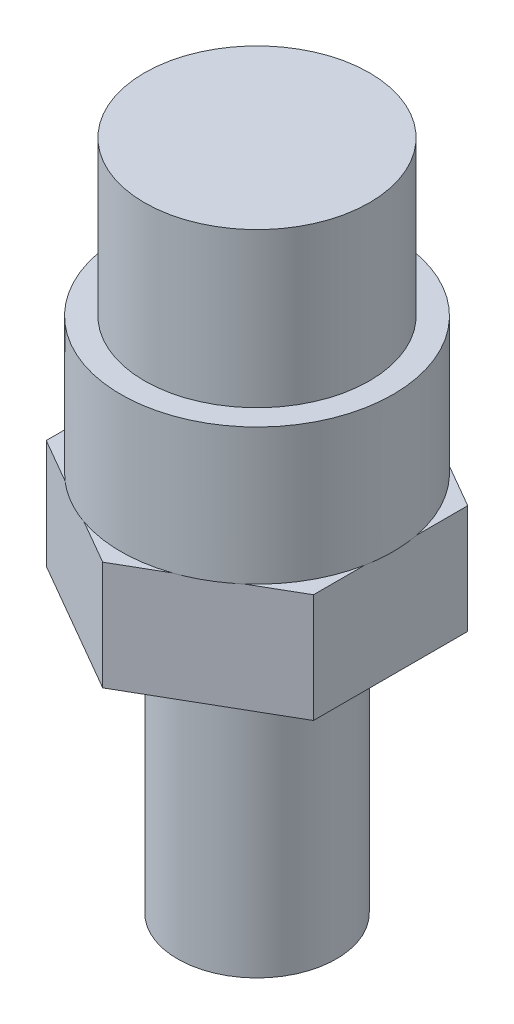
from build123d import *

# Parameters (mm, degrees)
CUT_EXTRUDE1_DEPTH = 7.62


with BuildPart() as part:
    # Sketch1 → Revolve1 (revolve)
    with BuildSketch(Plane.XY):
        Polygon((0, 0), (5.55625, 0), (5.55625, 19.05), (10.795, 19.05), (10.795, 26.67), (9.525, 26.67), (9.525, 36.195), (7.874, 36.195), (7.874, 46.99), (0, 46.99), align=None)
    revolve(axis=Axis((0, 46.99, 0), (0, -1, 0)))

    # Sketch2 → Cut-Extrude1 (cut)
    with BuildSketch(Plane.XZ.offset(-19.05)):
        with BuildLine():
            Line((-9.348744234, 5.3975), (0, 10.795))
            ThreePointArc((0, 10.795), (-5.3975, 9.348744234), (-9.348744234, 5.3975))
        make_face()
        with BuildLine():
            ThreePointArc((9.348744234, 5.3975), (5.3975, 9.348744234), (0, 10.795))
            Line((0, 10.795), (9.348744234, 5.3975))
        make_face()
        with BuildLine():
            ThreePointArc((10.795, 0), (10.427169295, 2.793951592), (9.348744234, 5.3975))
            Line((9.348744234, 5.3975), (9.348744234, -5.3975))
            ThreePointArc((9.348744234, -5.3975), (10.427169295, -2.793951592), (10.795, 0))
        make_face()
        with BuildLine():
            ThreePointArc((0, -10.795), (5.3975, -9.348744234), (9.348744234, -5.3975))
            Line((9.348744234, -5.3975), (0, -10.795))
        make_face()
        with BuildLine():
            Line((0, -10.795), (-9.348744234, -5.3975))
            ThreePointArc((-9.348744234, -5.3975), (-5.3975, -9.348744234), (0, -10.795))
        make_face()
        with BuildLine():
            Line((-9.348744234, -5.3975), (-9.348744234, 5.3975))
            ThreePointArc((-9.348744234, 5.3975), (-10.795, 0), (-9.348744234, -5.3975))
        make_face()
    extrude(amount=-CUT_EXTRUDE1_DEPTH, mode=Mode.SUBTRACT)


solid = part.part
